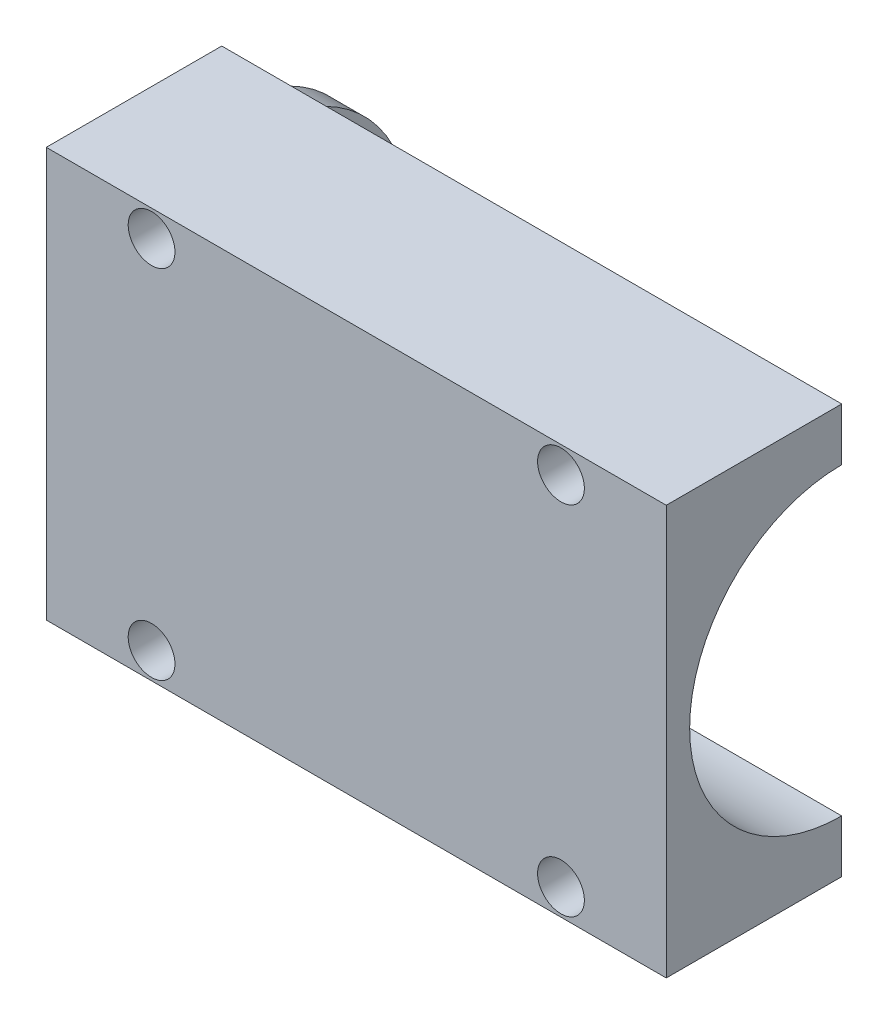
from build123d import *

# Parameters (mm, degrees)
SKETCH1_W           = 53
SKETCH1_H           = 35
BOSS_EXTRUDE1_DEPTH = 15
SKETCH3_R           = 13
CUT_EXTRUDE1_DEPTH  = 50
BOSS_EXTRUDE4_START = -3
SKETCH6_R           = 13
BOSS_EXTRUDE4_DEPTH = 3
SKETCH7_R           = 4.5
CUT_EXTRUDE2_DEPTH  = 54
SKETCH10_R          = 2
CUT_EXTRUDE3_DEPTH  = 16
SKETCH17_R          = 1.75
CUT_EXTRUDE5_DEPTH  = 4


with BuildPart() as part:
    # Sketch1 → Boss-Extrude1 (new body)
    with BuildSketch(Plane.XY):
        Rectangle(SKETCH1_W, SKETCH1_H)
    extrude(amount=BOSS_EXTRUDE1_DEPTH)

    # Sketch3 → Cut-Extrude1 (cut)
    with BuildSketch(Plane(origin=(26.5, 0, 0), x_dir=(0, 0, -1), z_dir=(1, 0, 0))):
        Circle(SKETCH3_R)
    extrude(amount=-CUT_EXTRUDE1_DEPTH, mode=Mode.SUBTRACT)

    # Sketch6 → Boss-Extrude4 (add)
    with BuildSketch(Plane.ZY.offset(26.5).offset(BOSS_EXTRUDE4_START)):
        Circle(SKETCH6_R)
    extrude(amount=BOSS_EXTRUDE4_DEPTH)

    # Sketch7 → Cut-Extrude2 (cut, through all)
    with BuildSketch(Plane.ZY.offset(26.5)):
        Circle(SKETCH7_R)
    extrude(amount=-CUT_EXTRUDE2_DEPTH, mode=Mode.SUBTRACT)

    # Sketch10 → Cut-Extrude3 (cut, through all)
    with BuildSketch(Plane(origin=(0, 0, 0), x_dir=(-1, 0, 0), z_dir=(0, 0, -1))):
        with Locations((-17.5, 15.25)):
            Circle(SKETCH10_R)
        with Locations((17.5, 15.25)):
            Circle(SKETCH10_R)
        with Locations((17.5, -15.25)):
            Circle(SKETCH10_R)
        with Locations((-17.5, -15.25)):
            Circle(SKETCH10_R)
    extrude(amount=-CUT_EXTRUDE3_DEPTH, mode=Mode.SUBTRACT)

    # Sketch17 → Cut-Extrude5 (cut, through all)
    with BuildSketch(Plane(origin=(-23.5, 0, 0), x_dir=(0, 0, -1), z_dir=(1, 0, 0))):
        with Locations((0, -8.5)):
            Circle(SKETCH17_R)
        with Locations((0, 8.5)):
            Circle(SKETCH17_R)
    extrude(amount=-CUT_EXTRUDE5_DEPTH, mode=Mode.SUBTRACT)


solid = part.part
